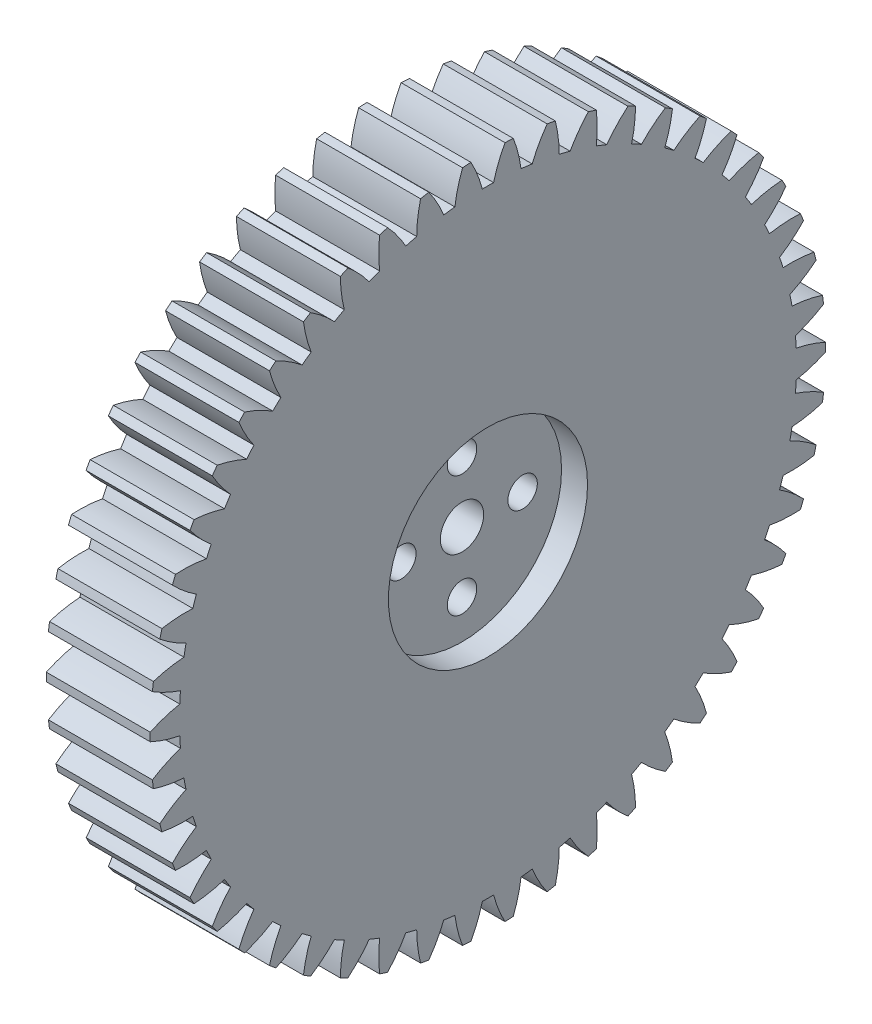
from build123d import *

# Parameters (mm, degrees)
BASPROSKE_W         = 12
BASPROSKE_H         = 39
TOOTHCUT_DEPTH      = 57.444663167
TEETHCUTS_COUNT     = 50
TEETHCUTS_ANGLE     = 352.8
BORSKE_R            = 4
BORE_DEPTH          = 50.0000508
SKETCH4_R           = 11.5
CUT_EXTRUDE1_DEPTH  = 3
SKETCH5_R           = 1.7
CUT_EXTRUDE2_DEPTH  = 12
SKETCH6_R           = 4
SKETCH6_R_2         = 2.5
BOSS_EXTRUDE1_DEPTH = 9
SKETCH7_R           = 11.25
CUT_EXTRUDE3_DEPTH  = 3


with BuildPart() as part:
    # BasProSke → Base-Revolve (revolve)
    with BuildSketch(Plane(origin=(0, 0, 0), x_dir=(1, 0, 0), z_dir=(0, 1, 0)), mode=Mode.PRIVATE) as base_revolve_sk:
        with Locations((6, 19.5)):
            Rectangle(BASPROSKE_W, BASPROSKE_H)
    revolve(base_revolve_sk.sketch.rotate(Axis((-10, 0, 0), (1, 0, 0)), 180), axis=Axis((-10, 0, 0), (1, 0, 0)))

    # TooCutSke → ToothCut (cut, through all)
    with BuildSketch(Plane(origin=(0, 0, 0), x_dir=(0, 0, -1), z_dir=(1, 0, 0))):
        with BuildLine():
            ThreePointArc((0.649974317, 35.618069984), (0, 35.624), (-0.649974317, 35.618069984))
            ThreePointArc((-0.649974317, 35.618069984), (-1.213667282, 37.336773563), (-1.980135572, 38.975131921))
            ThreePointArc((-1.980135572, 38.975131921), (0, 39.0254), (1.980135572, 38.975131921))
            ThreePointArc((1.980135572, 38.975131921), (1.213667282, 37.336773563), (0.649974317, 35.618069984))
        make_face()
    toothcut = extrude(amount=TOOTHCUT_DEPTH, mode=Mode.SUBTRACT)

    # TeethCuts: ToothCut ×50 about axis
    teethcuts_axis = Axis((-10, 0, 0), (1, 0, 0))
    for i in range(1, TEETHCUTS_COUNT):
        add(toothcut.rotate(teethcuts_axis, i * TEETHCUTS_ANGLE / (TEETHCUTS_COUNT - 1)), mode=Mode.SUBTRACT)

    # BorSke → Bore (cut, symmetric)
    with BuildSketch(Plane(origin=(0, 0, 0), x_dir=(0, 0, -1), z_dir=(1, 0, 0))):
        with Locations(Location((0, 0, 0), (0, 0, 180))):
            Circle(BORSKE_R)
    extrude(amount=BORE_DEPTH, both=True, mode=Mode.SUBTRACT)

    # Sketch4 → Cut-Extrude1 (cut)
    with BuildSketch(Plane(origin=(12, 0, 0), x_dir=(0, 0, -1), z_dir=(1, 0, 0))):
        Circle(SKETCH4_R)
    extrude(amount=-CUT_EXTRUDE1_DEPTH, mode=Mode.SUBTRACT)

    # Sketch5 → Cut-Extrude2 (cut)
    with BuildSketch(Plane(origin=(9, 0, 0), x_dir=(0, 0, -1), z_dir=(1, 0, 0))):
        with Locations((0, 7)):
            Circle(SKETCH5_R)
        with Locations((7, 0)):
            Circle(SKETCH5_R)
        with Locations((0, -7)):
            Circle(SKETCH5_R)
        with Locations((-7, 0)):
            Circle(SKETCH5_R)
    extrude(amount=-CUT_EXTRUDE2_DEPTH, mode=Mode.SUBTRACT)

    # Sketch6 → Boss-Extrude1 (add)
    with BuildSketch(Plane.ZY):
        Circle(SKETCH6_R)
        Circle(SKETCH6_R_2, mode=Mode.SUBTRACT)
    extrude(amount=-BOSS_EXTRUDE1_DEPTH)

    # Sketch7 → Cut-Extrude3 (cut)
    with BuildSketch(Plane.ZY):
        Circle(SKETCH7_R)
    extrude(amount=-CUT_EXTRUDE3_DEPTH, mode=Mode.SUBTRACT)


solid = part.part
